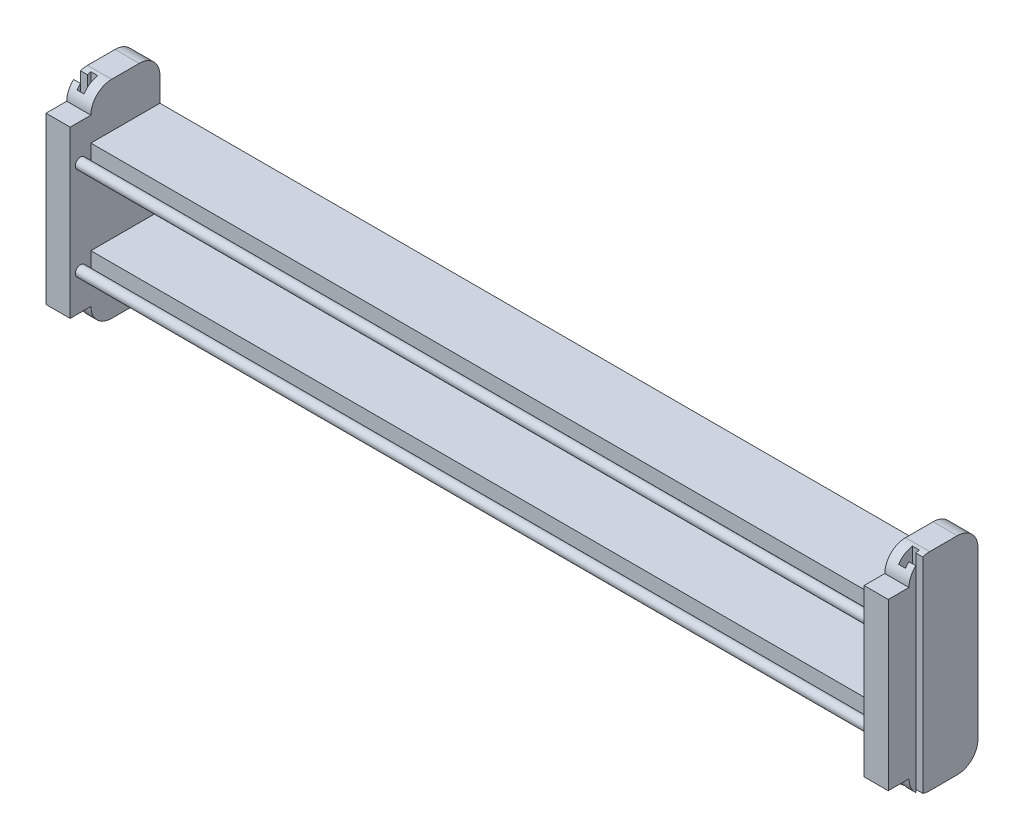
from build123d import *

# Parameters (mm, degrees)
SKETCH2_W           = 3098.8
SKETCH2_H           = 762
BOSS_EXTRUDE1_DEPTH = 254
SKETCH4_W           = 2921
SKETCH4_H           = 254
CUT_EXTRUDE2_DEPTH  = 255
SKETCH5_W           = 2921
SKETCH5_H           = 224.068342029
SKETCH5_H_2         = 209.470733182
CUT_EXTRUDE3_DEPTH  = 255
CUT_EXTRUDE5_START  = -762
CUT_EXTRUDE5_DEPTH  = 763
FILLET1_R           = 76.2
SKETCH9_W           = 88.9
SKETCH9_H           = 609.6
BOSS_EXTRUDE3_DEPTH = 76.2
SKETCH10_R          = 19.05
BOSS_EXTRUDE4_DEPTH = 2921


with BuildPart() as part:
    # Sketch2 → Boss-Extrude1 (new body)
    with BuildSketch(Plane.XY):
        Rectangle(SKETCH2_W, SKETCH2_H)
    extrude(amount=-BOSS_EXTRUDE1_DEPTH)

    # Sketch4 → Cut-Extrude2 (cut, through all)
    with BuildSketch(Plane.XY):
        Rectangle(SKETCH4_W, SKETCH4_H)
    extrude(amount=-CUT_EXTRUDE2_DEPTH, mode=Mode.SUBTRACT)

    # Sketch5 → Cut-Extrude3 (cut, through all)
    with BuildSketch(Plane.XY):
        with Locations((0, 327.934171015)):
            Rectangle(SKETCH5_W, SKETCH5_H)
        with Locations((0, -320.635366591)):
            Rectangle(SKETCH5_W, SKETCH5_H_2)
    extrude(amount=-CUT_EXTRUDE3_DEPTH, mode=Mode.SUBTRACT)

    # Sketch7 → Cut-Extrude5 (cut)
    with BuildSketch(Plane.XZ.offset(381).offset(CUT_EXTRUDE5_START)):
        Polygon((1524, -12.671415736), (1498.6, -12.671415736), (1498.6, -63.471415736), (1524, -63.471415736), (1524, -50.771415736), (1549.4, -50.771415736), (1549.4, -25.371415736), (1524, -25.371415736), align=None)
    cut_extrude5 = extrude(amount=CUT_EXTRUDE5_DEPTH, mode=Mode.SUBTRACT)

    # Mirror1: Cut-Extrude5 across plane
    add(cut_extrude5.mirror(Plane(origin=(0, 0, 0), x_dir=(0, 0, 1), z_dir=(1, 0, 0))), mode=Mode.SUBTRACT)

    # Fillet1
    fillet1_edges = [part.edges().sort_by_distance(p)[0] for p in [
        (-1504.95, -381, 0),
        (-1504.95, -381, -254),
        (-1504.95, 381, 0),
        (-1504.95, 381, -254),
        (1504.95, 381, 0),
        (1504.95, 381, -254),
        (1504.95, -381, -254),
        (1504.95, -381, 0),
    ]]
    fillet(fillet1_edges, radius=FILLET1_R)

    # Sketch9 → Boss-Extrude3 (add)
    with BuildSketch(Plane.XY):
        with Locations((1504.95, 0)):
            Rectangle(SKETCH9_W, SKETCH9_H)
    boss_extrude3 = extrude(amount=BOSS_EXTRUDE3_DEPTH)

    # Mirror6: Boss-Extrude3 across plane
    add(boss_extrude3.mirror(Plane(origin=(0, 0, 0), x_dir=(0, 0, 1), z_dir=(1, 0, 0))))

    # Sketch10 → Boss-Extrude4 (add)
    with BuildSketch(Plane(origin=(-1460.5, 0, 0), x_dir=(0, 0, -1), z_dir=(1, 0, 0))):
        with Locations((-38.1, -171.45)):
            Circle(SKETCH10_R)
    boss_extrude4 = extrude(amount=BOSS_EXTRUDE4_DEPTH)

    # Mirror7: Boss-Extrude4 across plane
    add(boss_extrude4.mirror(Plane.ZX))


solid = part.part
